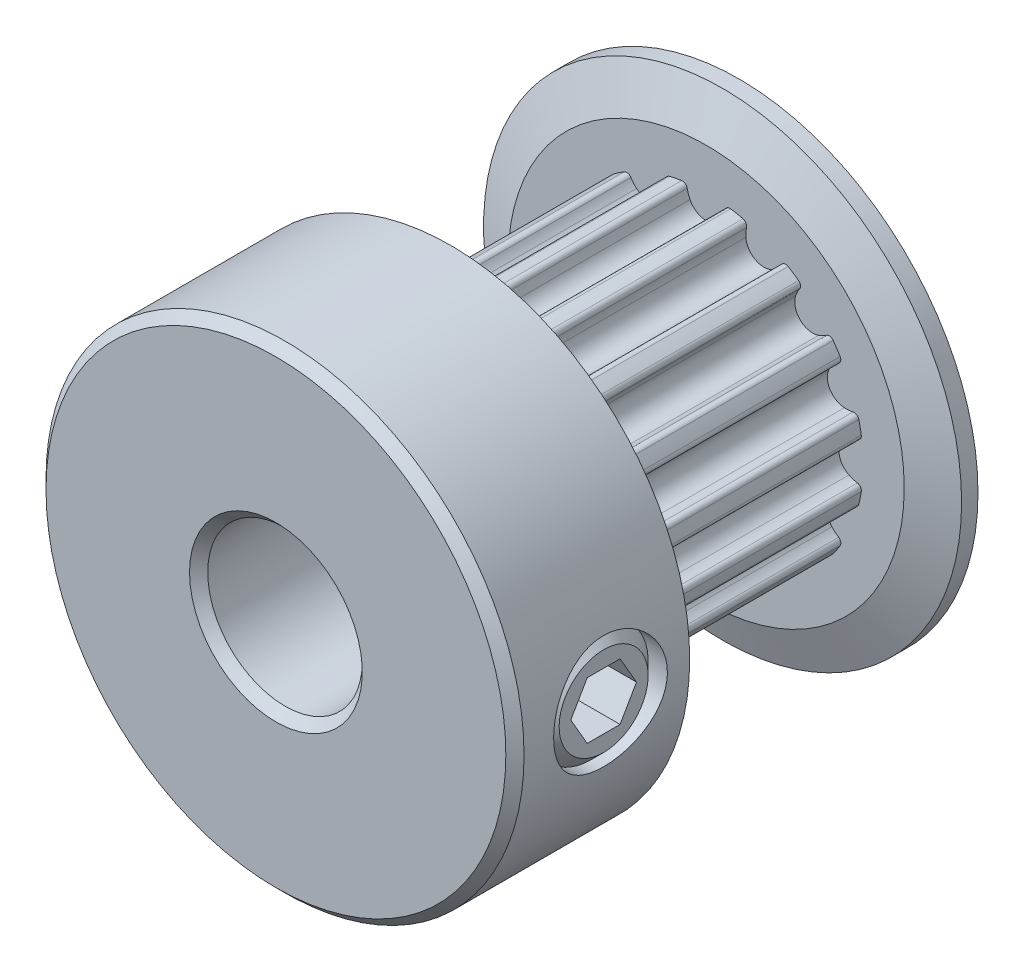
from build123d import *

# Parameters (mm, degrees)
CUT_EXTRUDE1_START = 1.245
CUT_EXTRUDE1_DEPTH = 7.37
CIRPATTERN1_COUNT  = 16
SKETCH4_R          = 1.7526
CUT_EXTRUDE2_DEPTH = 13.626327138
CUT_EXTRUDE3_DEPTH = 1.31445
CHAMFER1_SIZE      = 0.28075


with BuildPart() as part:
    # Sketch2 → Revolve1 (revolve)
    with BuildSketch(Plane(origin=(0, 0, 0), x_dir=(0, 0, -1), z_dir=(1, 0, 0)), mode=Mode.PRIVATE) as revolve1_sk:
        Polygon((-7.135, 2.38125), (7.135, 2.38125), (7.135, 7.366), (6.63, 7.366), (6.125, 6.10225), (6.125, 4.8385), (-1.245, 4.8385), (-1.245, 6.10225), (-1.75, 7.366), (-7.135, 7.366), align=None)
    revolve(revolve1_sk.sketch.rotate(Axis((0, 0, 7.135), (0, 0, -1)), 90), axis=Axis((0, 0, 7.135), (0, 0, -1)))

    # Sketch3 → Cut-Extrude1 (cut)
    with BuildSketch(Plane.XY.offset(CUT_EXTRUDE1_START)):
        with BuildLine():
            Line((3.073594629, 7.366), (-3.073594629, 7.366))
            Line((-3.073594629, 7.366), (-1.863248493, 4.465354107))
            ThreePointArc((-1.863248493, 4.465354107), (-1.318274781, 4.655452057), (-0.754542364, 4.779304141))
            ThreePointArc((-0.754542364, 4.779304141), (-0.64442881, 4.753529415), (-0.583609162, 4.658186341))
            ThreePointArc((-0.583609162, 4.658186341), (-0.550034004, 4.526353573), (-0.498876404, 4.400297753))
            ThreePointArc((-0.498876404, 4.400297753), (0, 4.0885), (0.498876404, 4.400297753))
            ThreePointArc((0.498876404, 4.400297753), (0.550034004, 4.526353573), (0.583609162, 4.658186341))
            ThreePointArc((0.583609162, 4.658186341), (0.64442881, 4.753529415), (0.754542364, 4.779304141))
            ThreePointArc((0.754542364, 4.779304141), (1.318274781, 4.655452057), (1.863248493, 4.465354107))
            Line((1.863248493, 4.465354107), (3.073594629, 7.366))
        make_face()
    cut_extrude1 = extrude(amount=-CUT_EXTRUDE1_DEPTH, mode=Mode.SUBTRACT)

    # CirPattern1: Cut-Extrude1 ×16 about axis
    cirpattern1_axis = Axis((0, 0, 0), (0, 0, 1))
    for i in range(1, CIRPATTERN1_COUNT):
        add(cut_extrude1.rotate(cirpattern1_axis, i * 360 / CIRPATTERN1_COUNT), mode=Mode.SUBTRACT)

    # Sketch4 → Cut-Extrude2 (cut, through all)
    with BuildSketch(Plane(origin=(0, 0, 0), x_dir=(0, -1, 0), z_dir=(1, 0, 0))):
        with Locations(Location((0, -4.19, 0), (0, 0, 270))):
            Circle(SKETCH4_R)
    extrude(amount=CUT_EXTRUDE2_DEPTH, mode=Mode.SUBTRACT)

    # Sketch5 → Revolve2 (revolve)
    with BuildSketch(Plane.XY.offset(4.19), mode=Mode.PRIVATE) as revolve2_sk:
        Polygon((2.38125, -1.3716), (2.38125, 0), (7.154463589, 0), (7.154463589, -1.3716), (6.773463589, -1.7526), (2.76225, -1.7526), align=None)
    revolve(revolve2_sk.sketch.rotate(Axis((2.38125, 0, 4.19), (1, 0, 0)), 270), axis=Axis((2.38125, 0, 4.19), (1, 0, 0)))

    # Sketch6 → Cut-Extrude3 (cut)
    with BuildSketch(Plane(origin=(7.154463589, 5.384140679, 0), x_dir=(0, -1, 0), z_dir=(-1, 0, 0))):
        Polygon((5.384140679, 5.201864082), (4.507840679, 4.695932041), (4.507840679, 3.684067959), (5.384140679, 3.178135918), (6.260440679, 3.684067959), (6.260440679, 4.695932041), align=None)
    extrude(amount=CUT_EXTRUDE3_DEPTH, mode=Mode.SUBTRACT)

    # Chamfer1
    chamfer1_edges = [part.edges().sort_by_distance(p)[0] for p in [
        (-2.38125, 0, 7.135),
        (-7.366, 0, 7.135),
    ]]
    chamfer(chamfer1_edges, length=CHAMFER1_SIZE)


solid = part.part
